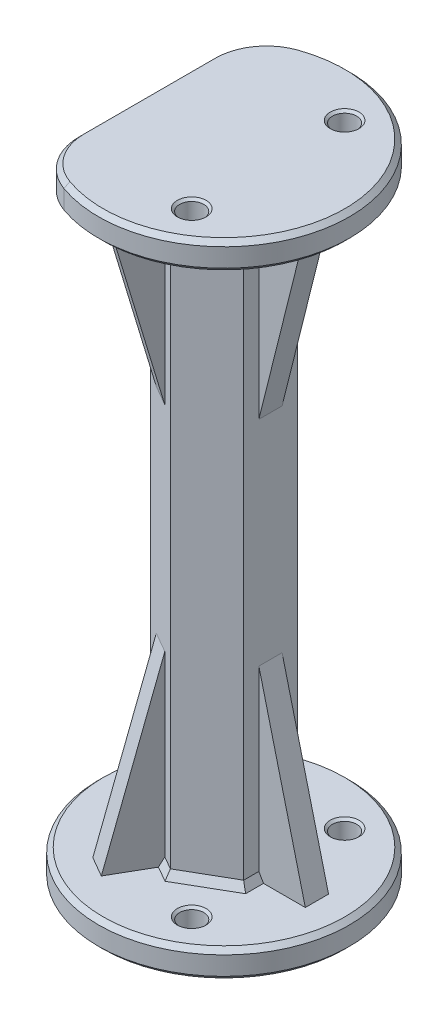
from build123d import *
from OCP.BRepFilletAPI import BRepFilletAPI_MakeChamfer

# Parameters (mm, degrees)
SKETCH3_R               = 27
BOSS_EXTRUDE1_DEPTH     = 6
BOSS_EXTRUDE2_DEPTH     = 126
SKETCH19_R              = 27
BOSS_EXTRUDE3_DEPTH     = 6
CUT_EXTRUDE5_REACH      = 139.412
SKETCH13_R              = 2.6
CUT_EXTRUDE6_REACH      = 145.185
SKETCH20_R              = 2.6
CUT_EXTRUDE7_REACH      = 145.185
SKETCH21_W              = 10
SKETCH21_H              = 41.952353926
RIB3_REACH              = 145.185
SKETCH18_WALL_W         = 329.601445786
SKETCH18_WALL_H         = 5
CIRPATTERN1_COUNT       = 3
MIRROR2_COPY_1_REACH    = 145.185
MIRROR2_COPY_1_SKETCH_W = 329.601445786
MIRROR2_COPY_1_SKETCH_H = 5
MIRROR2_COPY_2_REACH    = 145.185
MIRROR2_COPY_2_SKETCH_W = 329.601445786
MIRROR2_COPY_2_SKETCH_H = 5
FILLET1_R               = 12
CHAMFER1_SIZE           = 1
CHAMFER1_SIZE2          = 1.732050808
CHAMFER2_SIZE           = 1
CHAMFER3_SIZE           = 0.5


with BuildPart() as part:
    # Sketch3 → Boss-Extrude1 (new body)
    with BuildSketch(Plane(origin=(0, 0, 0), x_dir=(1, 0, 0), z_dir=(0, 1, 0))):
        with Locations(Location((0, 0, 0), (0, 0, 270))):
            Circle(SKETCH3_R)
    extrude(amount=BOSS_EXTRUDE1_DEPTH)

    # Sketch4 → Boss-Extrude2 (add)
    with BuildSketch(Plane(origin=(0, 6, 0), x_dir=(1, 0, 0), z_dir=(0, 1, 0))):
        Polygon((10, -5.773502692), (10, 5.773502692), (0, 11.547005384), (-10, 5.773502692), (-10, -5.773502692), (0, -11.547005384), align=None)
    extrude(amount=BOSS_EXTRUDE2_DEPTH)

    # Sketch19 → Boss-Extrude3 (add)
    with BuildSketch(Plane(origin=(0, 132, 0), x_dir=(1, 0, 0), z_dir=(0, 1, 0))):
        with Locations(Location((0, 0, 0), (0, 0, 270))):
            Circle(SKETCH19_R)
    extrude(amount=BOSS_EXTRUDE3_DEPTH)

    # Sketch13 → Cut-Extrude5 (cut, up to next)
    with BuildSketch(Plane(origin=(0, 6, 0), x_dir=(1, 0, 0), z_dir=(0, 1, 0)), mode=Mode.PRIVATE) as cut_extrude5_sk1:
        with Locations(Location((-19, 0, 0), (0, 0, 270))):
            Circle(SKETCH13_R)
    cut_extrude5_tool1 = extrude(cut_extrude5_sk1.sketch, amount=-CUT_EXTRUDE5_REACH, mode=Mode.PRIVATE) & part.part
    # Sketch13 → Cut-Extrude5 (cut, up to next)
    with BuildSketch(Plane(origin=(0, 6, 0), x_dir=(1, 0, 0), z_dir=(0, 1, 0)), mode=Mode.PRIVATE) as cut_extrude5_sk2:
        with Locations(Location((9.5, 16.454482672, 0), (0, 0, 270))):
            Circle(SKETCH13_R)
    cut_extrude5_tool2 = extrude(cut_extrude5_sk2.sketch, amount=-CUT_EXTRUDE5_REACH, mode=Mode.PRIVATE) & part.part
    # Sketch13 → Cut-Extrude5 (cut, up to next)
    with BuildSketch(Plane(origin=(0, 6, 0), x_dir=(1, 0, 0), z_dir=(0, 1, 0)), mode=Mode.PRIVATE) as cut_extrude5_sk3:
        with Locations(Location((9.5, -16.454482672, 0), (0, 0, 270))):
            Circle(SKETCH13_R)
    cut_extrude5_tool3 = extrude(cut_extrude5_sk3.sketch, amount=-CUT_EXTRUDE5_REACH, mode=Mode.PRIVATE) & part.part
    add(cut_extrude5_tool1.solids().sort_by_distance((-19, 6, 0))[0], mode=Mode.SUBTRACT)
    add(cut_extrude5_tool2.solids().sort_by_distance((9.5, 6, -16.454483))[0], mode=Mode.SUBTRACT)
    add(cut_extrude5_tool3.solids().sort_by_distance((9.5, 6, 16.454483))[0], mode=Mode.SUBTRACT)

    # Sketch20 → Cut-Extrude6 (cut, up to next)
    with BuildSketch(Plane(origin=(0, 138, 0), x_dir=(1, 0, 0), z_dir=(0, 1, 0)), mode=Mode.PRIVATE) as cut_extrude6_sk1:
        with Locations(Location((9.5, 16.454482672, 0), (0, 0, 270))):
            Circle(SKETCH20_R)
    cut_extrude6_tool1 = extrude(cut_extrude6_sk1.sketch, amount=-CUT_EXTRUDE6_REACH, mode=Mode.PRIVATE) & part.part
    # Sketch20 → Cut-Extrude6 (cut, up to next)
    with BuildSketch(Plane(origin=(0, 138, 0), x_dir=(1, 0, 0), z_dir=(0, 1, 0)), mode=Mode.PRIVATE) as cut_extrude6_sk2:
        with Locations(Location((9.5, -16.454482672, 0), (0, 0, 270))):
            Circle(SKETCH20_R)
    cut_extrude6_tool2 = extrude(cut_extrude6_sk2.sketch, amount=-CUT_EXTRUDE6_REACH, mode=Mode.PRIVATE) & part.part
    add(cut_extrude6_tool1.solids().sort_by_distance((9.5, 138, -16.454483))[0], mode=Mode.SUBTRACT)
    add(cut_extrude6_tool2.solids().sort_by_distance((9.5, 138, 16.454483))[0], mode=Mode.SUBTRACT)

    # Sketch21 → Cut-Extrude7 (cut, up to next)
    with BuildSketch(Plane(origin=(0, 138, 0), x_dir=(1, 0, 0), z_dir=(0, 1, 0)), mode=Mode.PRIVATE) as cut_extrude7_sk1:
        with Locations((-22, 0)):
            Rectangle(SKETCH21_W, SKETCH21_H)
    cut_extrude7_tool1 = extrude(cut_extrude7_sk1.sketch, amount=-CUT_EXTRUDE7_REACH, mode=Mode.PRIVATE) & part.part
    add(cut_extrude7_tool1.solids().sort_by_distance((-22, 138, 0))[0], mode=Mode.SUBTRACT)

    # Sketch18 wall → Rib3 (add, up to next)
    with BuildSketch(Plane(origin=(15, 26, 0), x_dir=(0.242535625036, -0.970142500145, 0), z_dir=(0.970142500145, 0.242535625036, 0)), mode=Mode.PRIVATE) as rib3_sk1:
        Rectangle(SKETCH18_WALL_W, SKETCH18_WALL_H)
    rib3_tool1 = extrude(rib3_sk1.sketch, amount=-RIB3_REACH, mode=Mode.PRIVATE) - part.part
    rib3 = rib3_tool1.solids().sort_by_distance((15, 26, 0))[0]
    add(rib3)

    # CirPattern1: Rib3 ×3 about axis
    cirpattern1_axis = Axis((0, 0, 0), (0, 1, 0))
    for i in range(1, CIRPATTERN1_COUNT):
        add(rib3.rotate(cirpattern1_axis, i * 360 / CIRPATTERN1_COUNT))

    # Mirror2: Rib3 across plane
    add(rib3.mirror(Plane.ZX.offset(69)))

    # Mirror2 copy 1 sketch → Mirror2 copy 1 (add, up to next)
    with BuildSketch(Plane(origin=(-7.5, 112, -12.990381057), x_dir=(-0.12126781251799995, 0.970142500145, -0.21004201260391314), z_dir=(-0.4850712500724998, -0.242535625036, -0.8401680504165185)), mode=Mode.PRIVATE) as mirror2_copy_1_sk1:
        Rectangle(MIRROR2_COPY_1_SKETCH_W, MIRROR2_COPY_1_SKETCH_H)
    mirror2_copy_1_tool1 = extrude(mirror2_copy_1_sk1.sketch, amount=-MIRROR2_COPY_1_REACH, mode=Mode.PRIVATE) - part.part
    add(mirror2_copy_1_tool1.solids().sort_by_distance((-7.5, 112, -12.990381057))[0])

    # Mirror2 copy 2 sketch → Mirror2 copy 2 (add, up to next)
    with BuildSketch(Plane(origin=(-7.5, 112, 12.990381057), x_dir=(-0.12126781251800012, 0.970142500145, 0.21004201260391306), z_dir=(-0.48507125007250046, -0.242535625036, 0.8401680504165182)), mode=Mode.PRIVATE) as mirror2_copy_2_sk1:
        Rectangle(MIRROR2_COPY_2_SKETCH_W, MIRROR2_COPY_2_SKETCH_H)
    mirror2_copy_2_tool1 = extrude(mirror2_copy_2_sk1.sketch, amount=-MIRROR2_COPY_2_REACH, mode=Mode.PRIVATE) - part.part
    add(mirror2_copy_2_tool1.solids().sort_by_distance((-7.5, 112, 12.990381057))[0])

    # Fillet1
    fillet1_edges = [part.edges().sort_by_distance(p)[0] for p in [
        (-17, 135, 20.976176963),
        (-17, 135, -20.976176963),
    ]]
    fillet(fillet1_edges, radius=FILLET1_R)

    # Chamfer1: one chamfer whose edges measure the first distance from different faces: ONE call of the kernel's chamfer builder (chamfer() names one face for all edges)
    chamfer1_edges_1 = [part.edges().sort_by_distance(p)[0] for p in [
        (10, 132, 4.136751346),
        (5, 132, -8.660254038),
        (-1.417468245, 132, -10.728629711),
        (-10, 132, 0),
        (-8.582531755, 132, 6.591878365),
        (10, 132, -4.136751346),
        (-1.417468245, 132, 10.728629711),
        (-8.582531755, 132, -6.591878365),
        (5, 132, 8.660254038),
    ]]
    chamfer1_side_1 = [part.faces().sort_by_distance(p)[0] for p in [
        (26.303437009, 132, 0),
    ]]
    chamfer1_edges_2 = [part.edges().sort_by_distance(p)[0] for p in [
        (-1.417468245, 6, 10.728629711),
        (-8.582531755, 6, -6.591878365),
        (10, 6, -4.136751346),
        (5, 6, 8.660254038),
        (10, 6, 4.136751346),
        (5, 6, -8.660254038),
        (-1.417468245, 6, -10.728629711),
        (-10, 6, 0),
        (-8.582531755, 6, 6.591878365),
    ]]
    chamfer1_side_2 = [part.faces().sort_by_distance(p)[0] for p in [
        (0, 6, -26.236324676),
    ]]
    chamfer1 = BRepFilletAPI_MakeChamfer(part.part.solid().wrapped)
    for e in chamfer1_edges_1:
        chamfer1.Add(CHAMFER1_SIZE, CHAMFER1_SIZE2, e.wrapped, chamfer1_side_1[0].wrapped)  # the first distance lies on this face
    for e in chamfer1_edges_2:
        chamfer1.Add(CHAMFER1_SIZE, CHAMFER1_SIZE2, e.wrapped, chamfer1_side_2[0].wrapped)  # the first distance lies on this face
    add(Compound.cast(chamfer1.Shape()), mode=Mode.REPLACE)

    # Chamfer2
    chamfer2_edges = [part.edges().sort_by_distance(p)[0] for p in [
        (0, 0, -27),
        (-17, 138, 0),
        (-17, 132, 0),
        (27, 132, 0),
        (-14.797958971, 132, 21.070338854),
        (-14.797958971, 132, -21.070338854),
        (27, 138, 0),
        (-14.797958971, 138, 21.070338854),
        (-14.797958971, 138, -21.070338854),
        (0, 6, -27),
    ]]
    chamfer(chamfer2_edges, length=CHAMFER2_SIZE)

    # Chamfer3
    chamfer3_edges = [part.edges().sort_by_distance(p)[0] for p in [
        (-19, 6, -2.6),
        (-19, 0, -2.6),
        (9.5, 6, -19.054482672),
        (9.5, 0, -19.054482672),
        (9.5, 6, 13.854482672),
        (9.5, 0, 13.854482672),
        (9.5, 132, -19.054482672),
        (9.5, 138, -19.054482672),
        (9.5, 132, 13.854482672),
        (9.5, 138, 13.854482672),
    ]]
    chamfer(chamfer3_edges, length=CHAMFER3_SIZE)


solid = part.part
